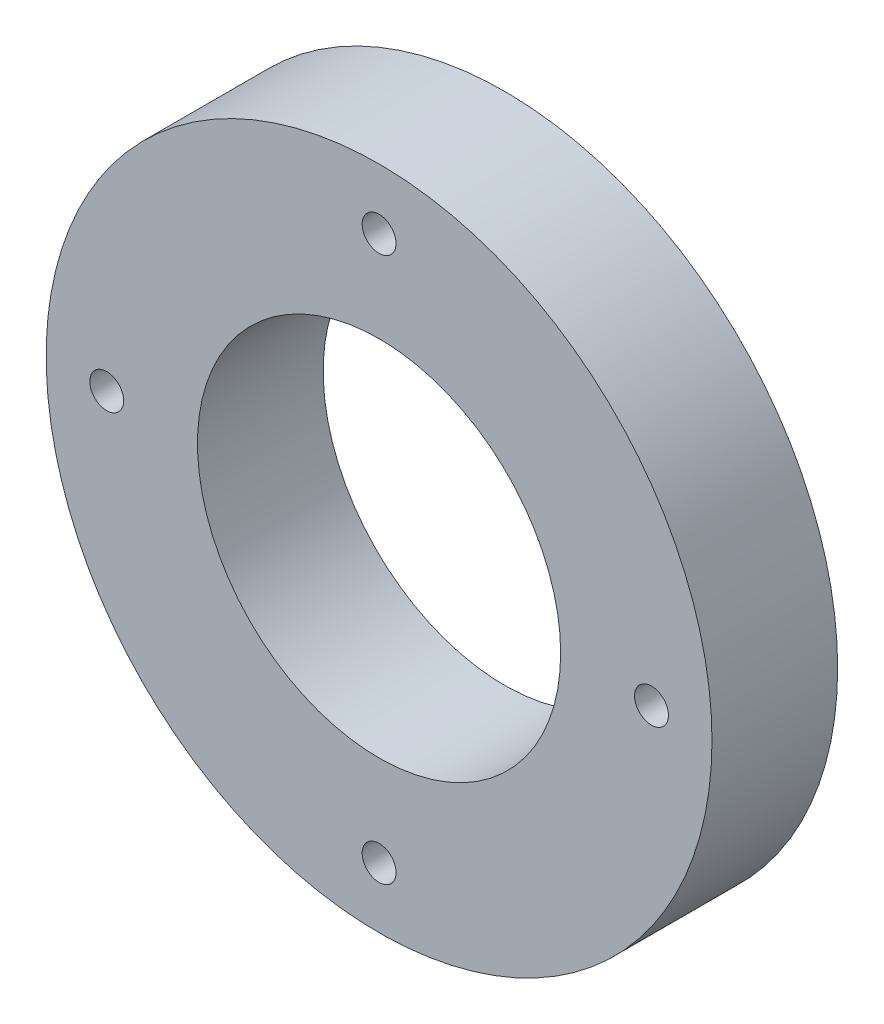
from build123d import *

# Parameters (mm, degrees)
SKETCH1_R           = 34.925
SKETCH1_R_2         = 19.05
SKETCH1_R_3         = 1.778
BOSS_EXTRUDE1_DEPTH = 13.1826


with BuildPart() as part:
    # Sketch1 → Boss-Extrude1 (new body)
    with BuildSketch(Plane.XY):
        Circle(SKETCH1_R)
        Circle(SKETCH1_R_2, mode=Mode.SUBTRACT)
        with Locations((0, 28.575)):
            Circle(SKETCH1_R_3, mode=Mode.SUBTRACT)
        with Locations((28.575, 0)):
            Circle(SKETCH1_R_3, mode=Mode.SUBTRACT)
        with Locations((0, -28.575)):
            Circle(SKETCH1_R_3, mode=Mode.SUBTRACT)
        with Locations((-28.575, 0)):
            Circle(SKETCH1_R_3, mode=Mode.SUBTRACT)
    extrude(amount=BOSS_EXTRUDE1_DEPTH)


solid = part.part
